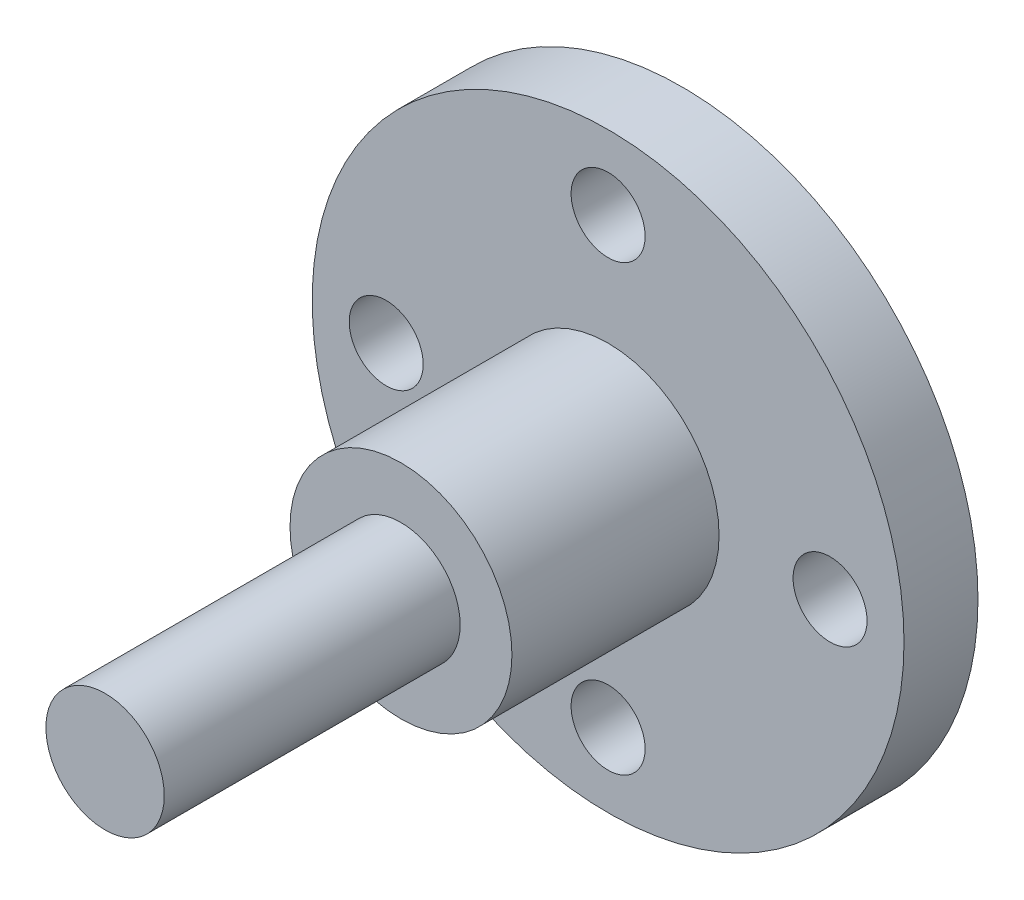
from build123d import *

# Parameters (mm, degrees)
SKETCH1_R           = 20
BOSS_EXTRUDE1_DEPTH = 5
SKETCH2_R           = 7.5
BOSS_EXTRUDE2_DEPTH = 14
SKETCH3_R           = 4
BOSS_EXTRUDE3_DEPTH = 20
SKETCH4_R           = 2.5
CUT_EXTRUDE1_DEPTH  = 20


with BuildPart() as part:
    # Sketch1 → Boss-Extrude1 (new body)
    with BuildSketch(Plane.XY):
        Circle(SKETCH1_R)
    extrude(amount=BOSS_EXTRUDE1_DEPTH)

    # Sketch2 → Boss-Extrude2 (add)
    with BuildSketch(Plane.XY.offset(5)):
        Circle(SKETCH2_R)
    extrude(amount=BOSS_EXTRUDE2_DEPTH)

    # Sketch3 → Boss-Extrude3 (add)
    with BuildSketch(Plane.XY.offset(19)):
        Circle(SKETCH3_R)
    extrude(amount=BOSS_EXTRUDE3_DEPTH)

    # Sketch4 → Cut-Extrude1 (cut)
    with BuildSketch(Plane.XY.offset(5)):
        with Locations((0, 15)):
            Circle(SKETCH4_R)
        with Locations((15, 0)):
            Circle(SKETCH4_R)
        with Locations((0, -15)):
            Circle(SKETCH4_R)
        with Locations((-15, 0)):
            Circle(SKETCH4_R)
    extrude(amount=-CUT_EXTRUDE1_DEPTH, mode=Mode.SUBTRACT)


solid = part.part
